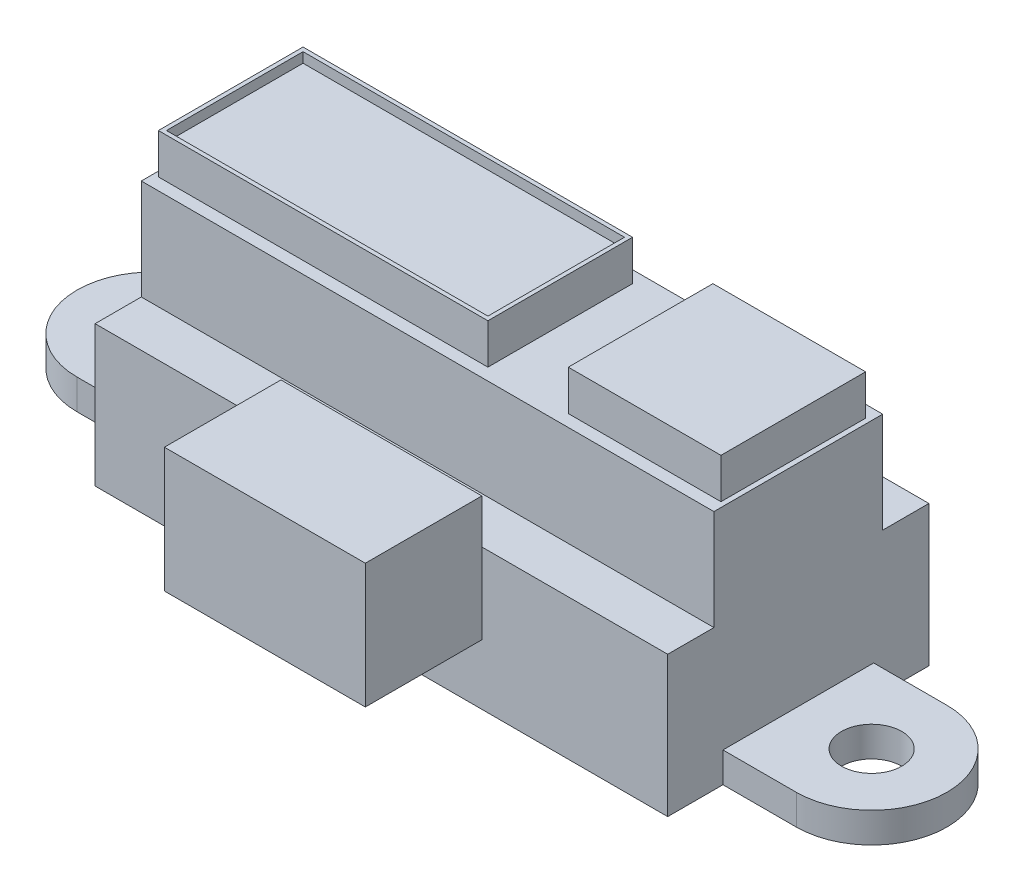
from build123d import *

# Parameters (mm, degrees)
SKETCH1_W           = 28.5
SKETCH1_H           = 13
BOSS_EXTRUDE1_DEPTH = 7
SKETCH2_W           = 28.5
SKETCH2_H           = 8.4
BOSS_EXTRUDE2_DEPTH = 5
SKETCH4_W           = 16.4
SKETCH4_H           = 7.2
SKETCH4_W_2         = 7.6
BOSS_EXTRUDE3_DEPTH = 2
SKETCH5_W           = 16
SKETCH5_H           = 6.8
CUT_EXTRUDE1_DEPTH  = 0.5
SKETCH6_R           = 1.5
BOSS_EXTRUDE4_DEPTH = 1.5
SKETCH7_W           = 10
SKETCH7_H           = 5.8
BOSS_EXTRUDE5_DEPTH = 6.2


with BuildPart() as part:
    # Sketch1 → Boss-Extrude1 (new body)
    with BuildSketch(Plane(origin=(0, 0, 0), x_dir=(1, 0, 0), z_dir=(0, 1, 0))):
        Rectangle(SKETCH1_W, SKETCH1_H)
    extrude(amount=BOSS_EXTRUDE1_DEPTH)

    # Sketch2 → Boss-Extrude2 (add)
    with BuildSketch(Plane(origin=(0, 7, 0), x_dir=(1, 0, 0), z_dir=(0, 1, 0))):
        Rectangle(SKETCH2_W, SKETCH2_H)
    extrude(amount=BOSS_EXTRUDE2_DEPTH)

    # Sketch4 → Boss-Extrude3 (add)
    with BuildSketch(Plane(origin=(0, 12, 0), x_dir=(1, 0, 0), z_dir=(0, 1, 0))):
        with Locations((-5.8, 0)):
            Rectangle(SKETCH4_W, SKETCH4_H)
        with Locations((10.2, 0)):
            Rectangle(SKETCH4_W_2, SKETCH4_H)
    extrude(amount=BOSS_EXTRUDE3_DEPTH)

    # Sketch5 → Cut-Extrude1 (cut)
    with BuildSketch(Plane(origin=(0, 14, 0), x_dir=(1, 0, 0), z_dir=(0, 1, 0))):
        with Locations((-5.8, 0)):
            Rectangle(SKETCH5_W, SKETCH5_H)
    extrude(amount=-CUT_EXTRUDE1_DEPTH, mode=Mode.SUBTRACT)

    # Sketch6 → Boss-Extrude4 (add)
    with BuildSketch(Plane(origin=(0, 0, 0), x_dir=(1, 0, 0), z_dir=(0, 1, 0))):
        with BuildLine():
            Line((-14.25, 3.75), (-14.25, -3.75))
            Line((-14.25, -3.75), (-17.9, -3.75))
            ThreePointArc((-17.9, -3.75), (-21.65, 0), (-17.9, 3.75))
            Line((-17.9, 3.75), (-14.25, 3.75))
        make_face()
        with Locations((-17.9, 0)):
            Circle(SKETCH6_R, mode=Mode.SUBTRACT)
    boss_extrude4 = extrude(amount=BOSS_EXTRUDE4_DEPTH)

    # Mirror1: Boss-Extrude4 across plane
    add(boss_extrude4.mirror(Plane(origin=(0, 0, 0), x_dir=(0, 0, 1), z_dir=(1, 0, 0))))

    # Sketch7 → Boss-Extrude5 (add)
    with BuildSketch(Plane(origin=(0, 3, 0), x_dir=(1, 0, 0), z_dir=(0, 1, 0))):
        with Locations((0, -9.4)):
            Rectangle(SKETCH7_W, SKETCH7_H)
    extrude(amount=BOSS_EXTRUDE5_DEPTH)


solid = part.part
